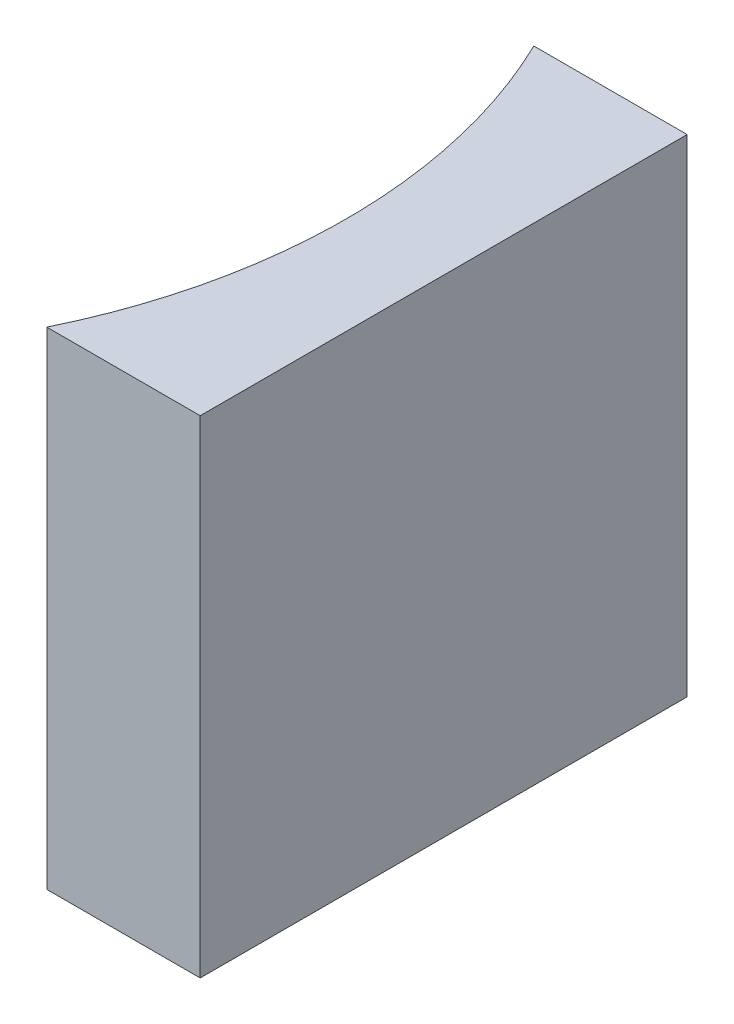
from build123d import *

# Parameters (mm, degrees)
EXTRUDE_1_DEPTH = 10


with BuildPart() as part:
    # 草图1 → 凸台-拉伸1 (new body)
    with BuildSketch(Plane(origin=(0, 0, 0), x_dir=(1, 0, 0), z_dir=(0, 1, 0))):
        with BuildLine():
            Line((0, 0), (0, -10))
            Line((0, -10), (-3.149393222, -10))
            ThreePointArc((-3.149393222, -10), (-2, -5), (-3.149393222, 0))
            Line((-3.149393222, 0), (0, 0))
        make_face()
    extrude(amount=EXTRUDE_1_DEPTH)


solid = part.part
